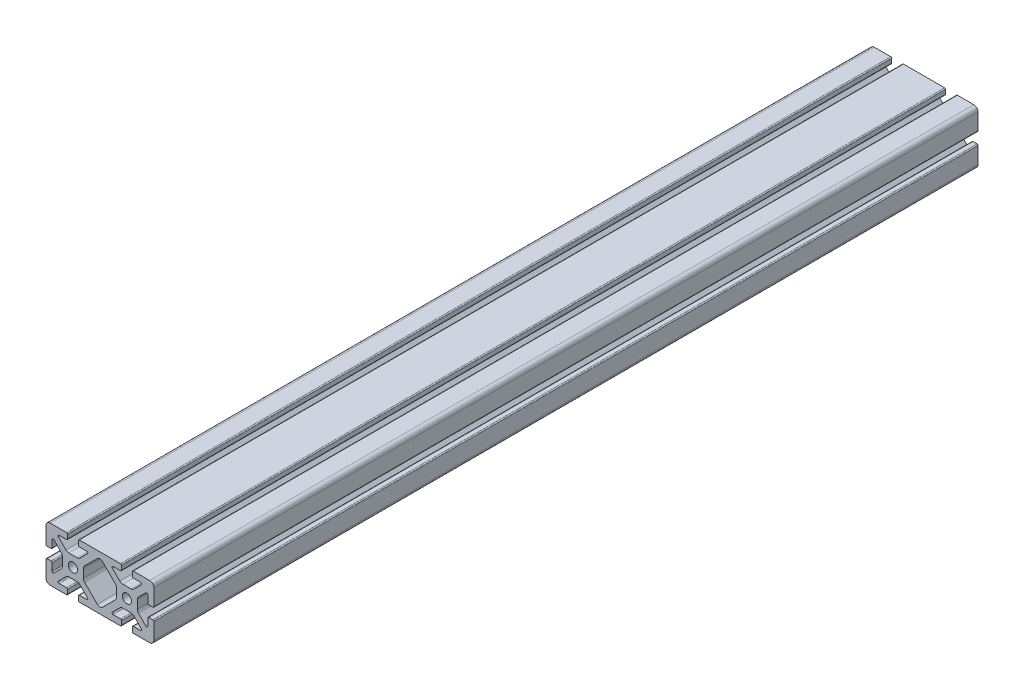
from build123d import *

# Parameters (mm, degrees)
SKETCH1_R           = 3.4036
BOSS_EXTRUDE1_DEPTH = 304.8


with BuildPart() as part:
    # Sketch1 → Boss-Extrude1 (new body, symmetric)
    with BuildSketch(Plane.XY):
        with BuildLine():
            Line((-39.878, 16.891), (-39.878, 4.7625))
            ThreePointArc((-39.878, 4.7625), (-39.654815367, 4.223684633), (-39.116, 4.0005))
            Line((-39.116, 4.0005), (-36.1442, 4.0005))
            ThreePointArc((-36.1442, 4.0005), (-35.605384633, 4.223684633), (-35.3822, 4.7625))
            Line((-35.3822, 4.7625), (-35.3822, 10.2235))
            ThreePointArc((-35.3822, 10.2235), (-34.911804775, 10.927496204), (-34.081384633, 10.762315367))
            Line((-34.081384633, 10.762315367), (-28.513059555, 5.19399029))
            ThreePointArc((-28.513059555, 5.19399029), (-27.863348265, 4.221628629), (-27.6352, 3.074649845))
            Line((-27.6352, 3.074649845), (-27.6352, -3.074649845))
            ThreePointArc((-27.6352, -3.074649845), (-27.863348265, -4.221628629), (-28.513059555, -5.19399029))
            Line((-28.513059555, -5.19399029), (-34.081384633, -10.762315367))
            ThreePointArc((-34.081384633, -10.762315367), (-34.911804775, -10.927496204), (-35.3822, -10.2235))
            Line((-35.3822, -10.2235), (-35.3822, -4.7625))
            ThreePointArc((-35.3822, -4.7625), (-35.605384633, -4.223684633), (-36.1442, -4.0005))
            Line((-36.1442, -4.0005), (-39.116, -4.0005))
            ThreePointArc((-39.116, -4.0005), (-39.654815367, -4.223684633), (-39.878, -4.7625))
            Line((-39.878, -4.7625), (-39.878, -16.891))
            ThreePointArc((-39.878, -16.891), (-38.985261469, -19.046261469), (-36.83, -19.939))
            Line((-36.83, -19.939), (-24.7015, -19.939))
            ThreePointArc((-24.7015, -19.939), (-24.162684633, -19.715815367), (-23.9395, -19.177))
            Line((-23.9395, -19.177), (-23.9395, -16.2052))
            ThreePointArc((-23.9395, -16.2052), (-24.162684633, -15.666384633), (-24.7015, -15.4432))
            Line((-24.7015, -15.4432), (-30.1625, -15.4432))
            ThreePointArc((-30.1625, -15.4432), (-30.866496204, -14.972804775), (-30.701315367, -14.142384633))
            Line((-30.701315367, -14.142384633), (-25.13299029, -8.574059555))
            ThreePointArc((-25.13299029, -8.574059555), (-24.160628629, -7.924348265), (-23.013649845, -7.6962))
            Line((-23.013649845, -7.6962), (-16.864350155, -7.6962))
            ThreePointArc((-16.864350155, -7.6962), (-15.717371371, -7.924348265), (-14.74500971, -8.574059555))
            Line((-14.74500971, -8.574059555), (-9.176684633, -14.142384633))
            ThreePointArc((-9.176684633, -14.142384633), (-9.011503796, -14.972804775), (-9.7155, -15.4432))
            Line((-9.7155, -15.4432), (-15.1765, -15.4432))
            ThreePointArc((-15.1765, -15.4432), (-15.715315367, -15.666384633), (-15.9385, -16.2052))
            Line((-15.9385, -16.2052), (-15.9385, -19.177))
            ThreePointArc((-15.9385, -19.177), (-15.715315367, -19.715815367), (-15.1765, -19.939))
            Line((-15.1765, -19.939), (15.1765, -19.939))
            ThreePointArc((15.1765, -19.939), (15.715315367, -19.715815367), (15.9385, -19.177))
            Line((15.9385, -19.177), (15.9385, -16.2052))
            ThreePointArc((15.9385, -16.2052), (15.715315367, -15.666384633), (15.1765, -15.4432))
            Line((15.1765, -15.4432), (9.7155, -15.4432))
            ThreePointArc((9.7155, -15.4432), (9.011503796, -14.972804775), (9.176684633, -14.142384633))
            Line((9.176684633, -14.142384633), (14.74500971, -8.574059555))
            ThreePointArc((14.74500971, -8.574059555), (15.717371371, -7.924348265), (16.864350155, -7.6962))
            Line((16.864350155, -7.6962), (23.013649845, -7.6962))
            ThreePointArc((23.013649845, -7.6962), (24.160628629, -7.924348265), (25.13299029, -8.574059555))
            Line((25.13299029, -8.574059555), (30.701315367, -14.142384633))
            ThreePointArc((30.701315367, -14.142384633), (30.866496204, -14.972804775), (30.1625, -15.4432))
            Line((30.1625, -15.4432), (24.7015, -15.4432))
            ThreePointArc((24.7015, -15.4432), (24.162684633, -15.666384633), (23.9395, -16.2052))
            Line((23.9395, -16.2052), (23.9395, -19.177))
            ThreePointArc((23.9395, -19.177), (24.162684633, -19.715815367), (24.7015, -19.939))
            Line((24.7015, -19.939), (36.83, -19.939))
            ThreePointArc((36.83, -19.939), (38.985261469, -19.046261469), (39.878, -16.891))
            Line((39.878, -16.891), (39.878, -4.7625))
            ThreePointArc((39.878, -4.7625), (39.654815367, -4.223684633), (39.116, -4.0005))
            Line((39.116, -4.0005), (36.1442, -4.0005))
            ThreePointArc((36.1442, -4.0005), (35.605384633, -4.223684633), (35.3822, -4.7625))
            Line((35.3822, -4.7625), (35.3822, -10.2235))
            ThreePointArc((35.3822, -10.2235), (34.911804775, -10.927496204), (34.081384633, -10.762315367))
            Line((34.081384633, -10.762315367), (28.513059555, -5.19399029))
            ThreePointArc((28.513059555, -5.19399029), (27.863348265, -4.221628629), (27.6352, -3.074649845))
            Line((27.6352, -3.074649845), (27.6352, 3.074649845))
            ThreePointArc((27.6352, 3.074649845), (27.863348265, 4.221628629), (28.513059555, 5.19399029))
            Line((28.513059555, 5.19399029), (34.081384633, 10.762315367))
            ThreePointArc((34.081384633, 10.762315367), (34.911804775, 10.927496204), (35.3822, 10.2235))
            Line((35.3822, 10.2235), (35.3822, 4.7625))
            ThreePointArc((35.3822, 4.7625), (35.605384633, 4.223684633), (36.1442, 4.0005))
            Line((36.1442, 4.0005), (39.116, 4.0005))
            ThreePointArc((39.116, 4.0005), (39.654815367, 4.223684633), (39.878, 4.7625))
            Line((39.878, 4.7625), (39.878, 16.891))
            ThreePointArc((39.878, 16.891), (38.985261469, 19.046261469), (36.83, 19.939))
            Line((36.83, 19.939), (24.7015, 19.939))
            ThreePointArc((24.7015, 19.939), (24.162684633, 19.715815367), (23.9395, 19.177))
            Line((23.9395, 19.177), (23.9395, 16.2052))
            ThreePointArc((23.9395, 16.2052), (24.162684633, 15.666384633), (24.7015, 15.4432))
            Line((24.7015, 15.4432), (30.1625, 15.4432))
            ThreePointArc((30.1625, 15.4432), (30.866496204, 14.972804775), (30.701315367, 14.142384633))
            Line((30.701315367, 14.142384633), (25.13299029, 8.574059555))
            ThreePointArc((25.13299029, 8.574059555), (24.160628629, 7.924348265), (23.013649845, 7.6962))
            Line((23.013649845, 7.6962), (16.864350155, 7.6962))
            ThreePointArc((16.864350155, 7.6962), (15.717371371, 7.924348265), (14.74500971, 8.574059555))
            Line((14.74500971, 8.574059555), (9.176684633, 14.142384633))
            ThreePointArc((9.176684633, 14.142384633), (9.011503796, 14.972804775), (9.7155, 15.4432))
            Line((9.7155, 15.4432), (15.1765, 15.4432))
            ThreePointArc((15.1765, 15.4432), (15.715315367, 15.666384633), (15.9385, 16.2052))
            Line((15.9385, 16.2052), (15.9385, 19.177))
            ThreePointArc((15.9385, 19.177), (15.715315367, 19.715815367), (15.1765, 19.939))
            Line((15.1765, 19.939), (-15.1765, 19.939))
            ThreePointArc((-15.1765, 19.939), (-15.715315367, 19.715815367), (-15.9385, 19.177))
            Line((-15.9385, 19.177), (-15.9385, 16.2052))
            ThreePointArc((-15.9385, 16.2052), (-15.715315367, 15.666384633), (-15.1765, 15.4432))
            Line((-15.1765, 15.4432), (-9.7155, 15.4432))
            ThreePointArc((-9.7155, 15.4432), (-9.011503796, 14.972804775), (-9.176684633, 14.142384633))
            Line((-9.176684633, 14.142384633), (-14.74500971, 8.574059555))
            ThreePointArc((-14.74500971, 8.574059555), (-15.717371371, 7.924348265), (-16.864350155, 7.6962))
            Line((-16.864350155, 7.6962), (-23.013649845, 7.6962))
            ThreePointArc((-23.013649845, 7.6962), (-24.160628629, 7.924348265), (-25.13299029, 8.574059555))
            Line((-25.13299029, 8.574059555), (-30.701315367, 14.142384633))
            ThreePointArc((-30.701315367, 14.142384633), (-30.866496204, 14.972804775), (-30.1625, 15.4432))
            Line((-30.1625, 15.4432), (-24.7015, 15.4432))
            ThreePointArc((-24.7015, 15.4432), (-24.162684633, 15.666384633), (-23.9395, 16.2052))
            Line((-23.9395, 16.2052), (-23.9395, 19.177))
            ThreePointArc((-23.9395, 19.177), (-24.162684633, 19.715815367), (-24.7015, 19.939))
            Line((-24.7015, 19.939), (-36.83, 19.939))
            ThreePointArc((-36.83, 19.939), (-38.985261469, 19.046261469), (-39.878, 16.891))
        make_face()
        with Locations((-19.939, 0)):
            Circle(SKETCH1_R, mode=Mode.SUBTRACT)
        with Locations((19.939, 0)):
            Circle(SKETCH1_R, mode=Mode.SUBTRACT)
        with BuildLine():
            Line((-12.2428, 3.074649845), (-12.2428, -3.074649845))
            ThreePointArc((-12.2428, -3.074649845), (-12.014651735, -4.221628629), (-11.364940445, -5.19399029))
            Line((-11.364940445, -5.19399029), (-1.904671503, -14.654259232))
            ThreePointArc((-1.904671503, -14.654259232), (0, -15.4432), (1.904671503, -14.654259232))
            Line((1.904671503, -14.654259232), (11.364940445, -5.19399029))
            ThreePointArc((11.364940445, -5.19399029), (12.014651735, -4.221628629), (12.2428, -3.074649845))
            Line((12.2428, -3.074649845), (12.2428, 3.074649845))
            ThreePointArc((12.2428, 3.074649845), (12.014651735, 4.221628629), (11.364940445, 5.19399029))
            Line((11.364940445, 5.19399029), (1.904671503, 14.654259232))
            ThreePointArc((1.904671503, 14.654259232), (0, 15.4432), (-1.904671503, 14.654259232))
            Line((-1.904671503, 14.654259232), (-11.364940445, 5.19399029))
            ThreePointArc((-11.364940445, 5.19399029), (-12.014651735, 4.221628629), (-12.2428, 3.074649845))
        make_face(mode=Mode.SUBTRACT)
    extrude(amount=BOSS_EXTRUDE1_DEPTH, both=True)


solid = part.part
